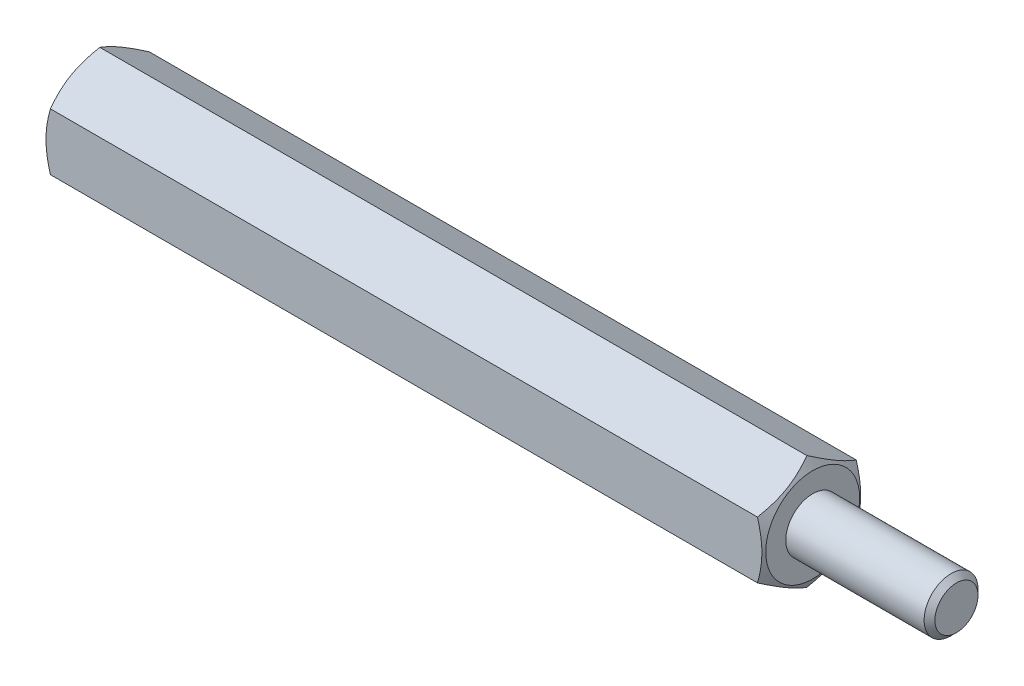
from build123d import *

# Parameters (mm, degrees)
BOSS_EXTRUDE1_DEPTH = 40
SKETCH2_R           = 1.5
BOSS_EXTRUDE2_DEPTH = 8
SKETCH3_R           = 1.5
CUT_EXTRUDE1_DEPTH  = 10
CHAMFER1_SIZE       = 0.3


with BuildPart() as part:
    # Sketch1 → Boss-Extrude1 (new body)
    with BuildSketch(Plane(origin=(0, 0, 0), x_dir=(0, 0, -1), z_dir=(1, 0, 0))):
        Polygon((0, 3.175426481), (-2.75, 1.58771324), (-2.75, -1.58771324), (0, -3.175426481), (2.75, -1.58771324), (2.75, 1.58771324), align=None)
    extrude(amount=BOSS_EXTRUDE1_DEPTH)

    # Sketch2 → Boss-Extrude2 (add)
    with BuildSketch(Plane(origin=(40, 0, 0), x_dir=(0, 0, -1), z_dir=(1, 0, 0))):
        Circle(SKETCH2_R)
    extrude(amount=BOSS_EXTRUDE2_DEPTH)

    # Sketch3 → Cut-Extrude1 (cut)
    with BuildSketch(Plane.ZY):
        Circle(SKETCH3_R)
    extrude(amount=-CUT_EXTRUDE1_DEPTH, mode=Mode.SUBTRACT)

    # Sketch4 → Cut-Revolve1 (revolve, cut)
    with BuildSketch(Plane(origin=(0, 0, 0), x_dir=(1, 0, 0), z_dir=(0, 1, 0))):
        Polygon((0, 10.219809024), (4.392081913, 10.219809024), (0, 2.6125), align=None)
        Polygon((40, 2.6125), (40, 10.219809024), (35.607918087, 10.219809024), align=None)
    revolve(axis=Axis((0, 0, 0), (-1, 0, 0)), mode=Mode.SUBTRACT)

    # Chamfer1
    chamfer1_edges = [part.edges().sort_by_distance(p)[0] for p in [
        (48, 0, 1.5),
    ]]
    chamfer(chamfer1_edges, length=CHAMFER1_SIZE)


solid = part.part
